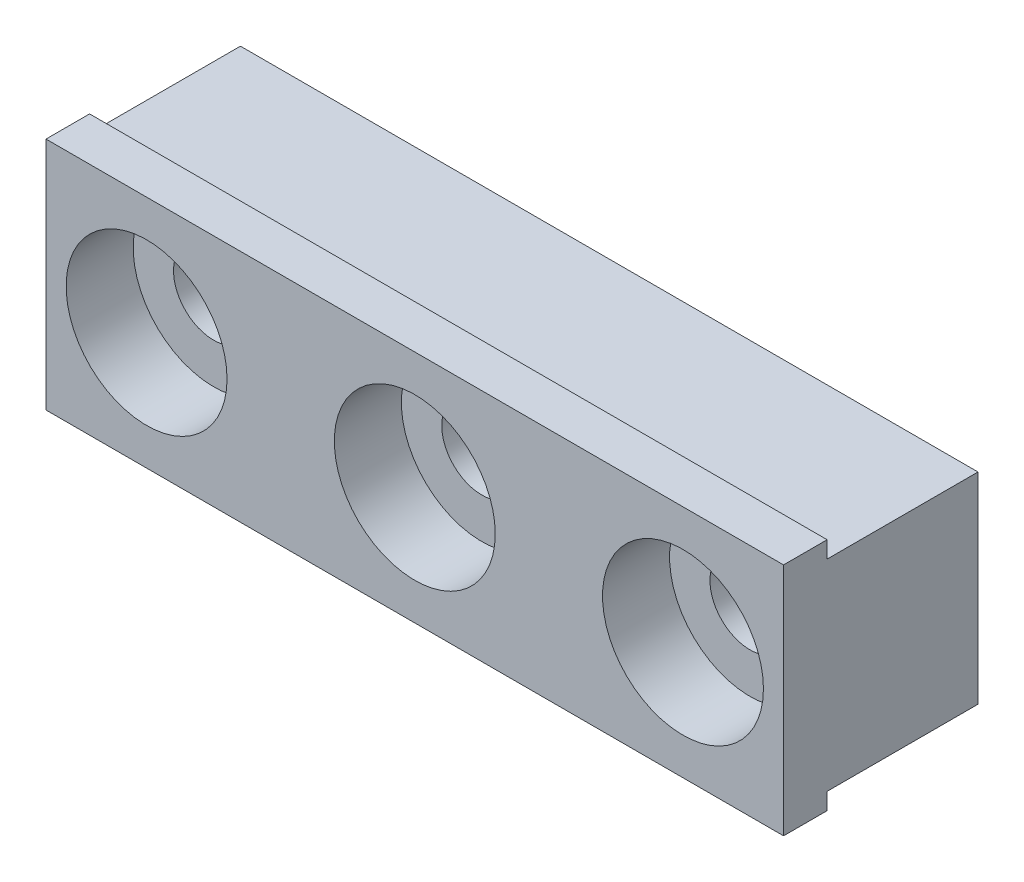
from build123d import *

# Parameters (mm, degrees)
SKETCH1_W                 = 34.925
SKETCH1_H                 = 9.525
BOSS_EXTRUDE1_DEPTH       = 7.14375
SKETCH2_W                 = 34.925
SKETCH2_H                 = 11.1125
BOSS_EXTRUDE2_DEPTH       = 2.06375
F_6_CLEARANCE_HOLE1_D     = 3.7973
F_6_CLEARANCE_HOLE1_DEPTH = 9.2075
SKETCH5_R                 = 3.81
CUT_EXTRUDE1_DEPTH        = 3.175


with BuildPart() as part:
    # Sketch1 → Boss-Extrude1 (new body)
    with BuildSketch(Plane.XY):
        with Locations((17.4625, 4.7625)):
            Rectangle(SKETCH1_W, SKETCH1_H)
    extrude(amount=BOSS_EXTRUDE1_DEPTH)

    # Sketch2 → Boss-Extrude2 (add)
    with BuildSketch(Plane.XY.offset(7.14375)):
        with Locations((17.4625, 4.7625)):
            Rectangle(SKETCH2_W, SKETCH2_H)
    extrude(amount=BOSS_EXTRUDE2_DEPTH)

    # #6 Clearance Hole1
    with Locations(Plane.XY.offset(9.2075)):
        with Locations((4.7625, 4.7625), (17.4625, 4.7625), (30.1625, 4.7625)):
            Hole(F_6_CLEARANCE_HOLE1_D / 2, depth=F_6_CLEARANCE_HOLE1_DEPTH)

    # Sketch5 → Cut-Extrude1 (cut)
    with BuildSketch(Plane.XY.offset(9.2075)):
        with Locations((4.7625, 4.7625)):
            Circle(SKETCH5_R)
        with Locations((17.4625, 4.7625)):
            Circle(SKETCH5_R)
        with Locations((30.1625, 4.7625)):
            Circle(SKETCH5_R)
    extrude(amount=-CUT_EXTRUDE1_DEPTH, mode=Mode.SUBTRACT)


solid = part.part
